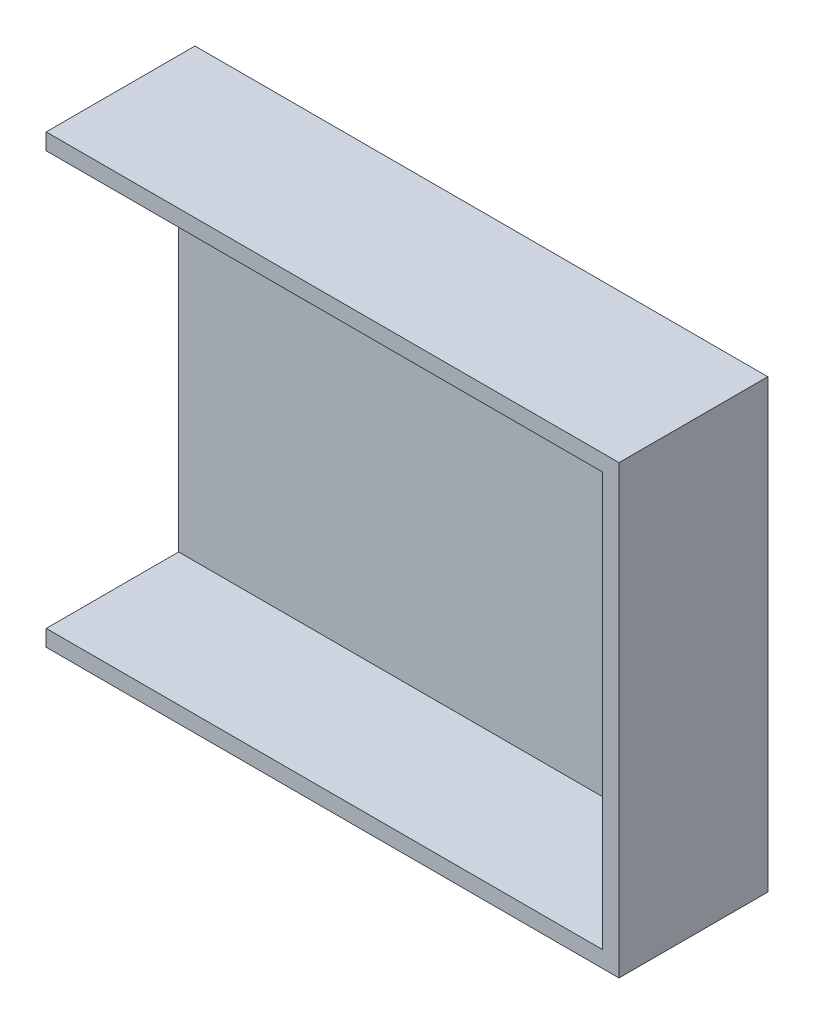
from build123d import *

# Parameters (mm, degrees)
SKETCH2_W           = 152.4
SKETCH2_H           = 195.58
BOSS_EXTRUDE1_DEPTH = 50.8
SHELL1_T            = -5.588


with BuildPart() as part:
    # Sketch2 → Boss-Extrude1 (new body)
    with BuildSketch(Plane(origin=(0, 0, 0), x_dir=(0, 1, 0), z_dir=(0, 0, 1))):
        with Locations((-114.3, 18.147782805)):
            Rectangle(SKETCH2_W, SKETCH2_H)
    extrude(amount=BOSS_EXTRUDE1_DEPTH)

    # Shell1
    shell1_openings = [part.faces().sort_by_distance(p)[0] for p in [
        (-18.147782805, -114.3, 50.8),
        (-115.937782805, -114.3, 25.4),
    ]]
    offset(amount=SHELL1_T, openings=shell1_openings, kind=Kind.INTERSECTION)


solid = part.part
